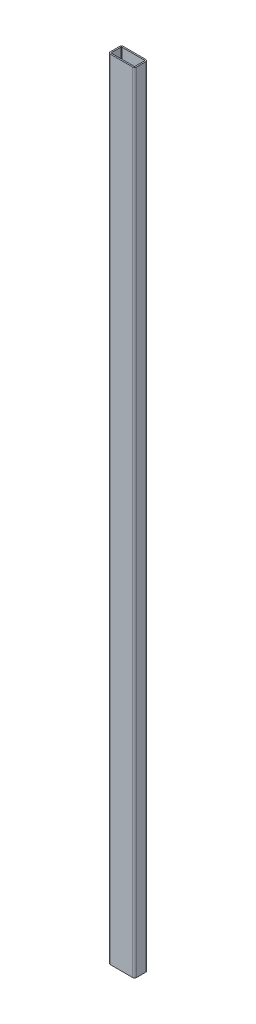
from build123d import *

# Parameters (mm, degrees)
EXTRUDE_1_DEPTH = 1200


with BuildPart() as part:
    # Эскиз1 → Вытянуть-Тонкостенный1 (new body)
    with BuildSketch(Plane(origin=(0, 0, 0), x_dir=(1, 0, 0), z_dir=(0, 1, 0))):
        with BuildLine():
            Line((3, 0), (37, 0))
            ThreePointArc((37, 0), (39.121320344, 0.878679656), (40, 3))
            Line((40, 3), (40, 17))
            ThreePointArc((40, 17), (39.121320344, 19.121320344), (37, 20))
            Line((37, 20), (3, 20))
            ThreePointArc((3, 20), (0.878679656, 19.121320344), (0, 17))
            Line((0, 17), (0, 3))
            ThreePointArc((0, 3), (0.878679656, 0.878679656), (3, 0))
        make_face()
        with BuildLine():
            Line((3, 2), (37, 2))
            ThreePointArc((37, 2), (37.707106781, 2.292893219), (38, 3))
            Line((38, 3), (38, 17))
            ThreePointArc((38, 17), (37.707106781, 17.707106781), (37, 18))
            Line((37, 18), (3, 18))
            ThreePointArc((3, 18), (2.292893219, 17.707106781), (2, 17))
            Line((2, 17), (2, 3))
            ThreePointArc((2, 3), (2.292893219, 2.292893219), (3, 2))
        make_face(mode=Mode.SUBTRACT)
    extrude(amount=EXTRUDE_1_DEPTH)


solid = part.part
